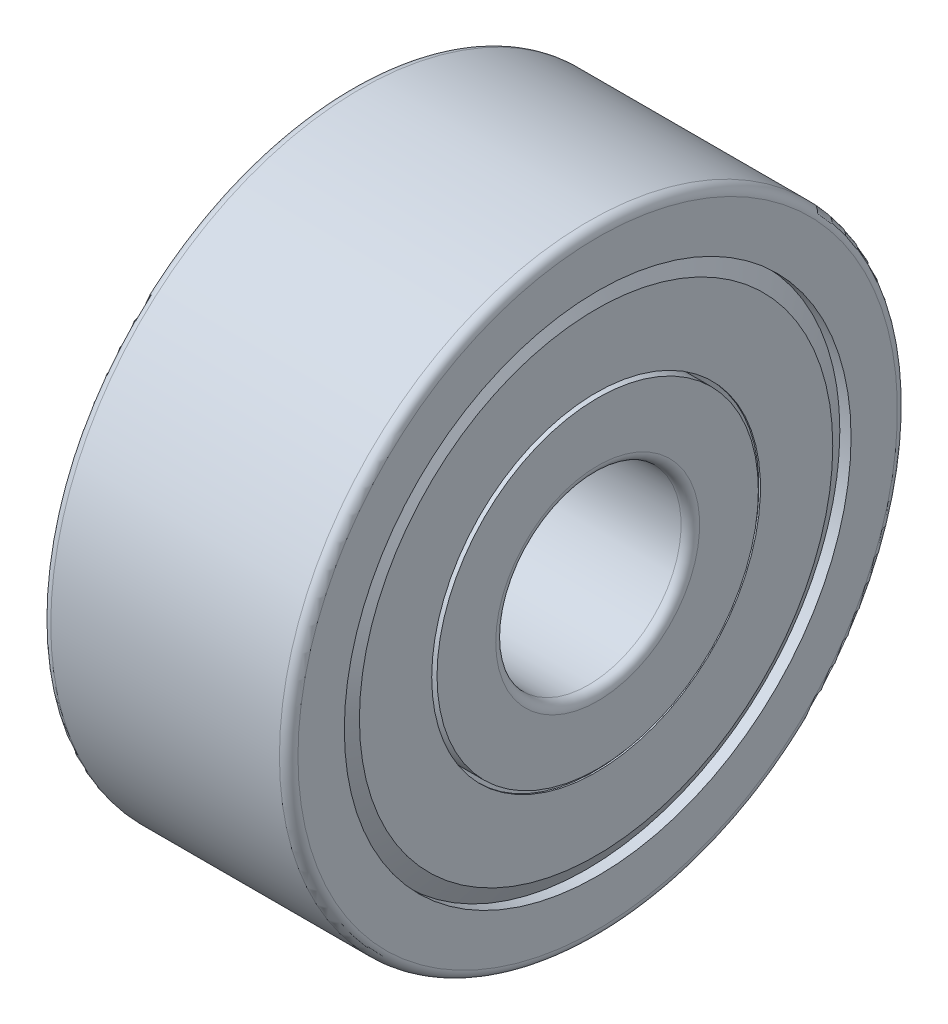
from build123d import *


with BuildPart() as part:
    # Esquisse1 → Révolution1 (revolve)
    with BuildSketch(Plane(origin=(0, 0, 0), x_dir=(-1, 0, 0), z_dir=(0, 0, -1))):
        with BuildLine():
            Line((-4, 2.6), (-4, 1.65))
            ThreePointArc((-4, 1.65), (-3.956066017, 1.543933983), (-3.85, 1.5))
            Line((-3.85, 1.5), (-0.15, 1.5))
            ThreePointArc((-0.15, 1.5), (-0.043933983, 1.543933983), (0, 1.65))
            Line((0, 1.65), (0, 2.6))
            Line((0, 2.6), (-0.887539014, 2.6))
            ThreePointArc((-0.887539014, 2.6), (-0.665814251, 3.208515617), (-0.754982151, 3.85))
            Line((-0.754982151, 3.85), (-0.363636364, 3.85))
            Line((-0.363636364, 3.85), (-0.363636364, 4.1))
            ThreePointArc((-0.363636364, 4.1), (-0.331965494, 4.168958654), (-0.259019853, 4.189869736))
            Line((-0.259019853, 4.189869736), (-0.261825318, 4.18825))
            Line((-0.261825318, 4.18825), (-0.051, 3.823089838))
            Line((-0.051, 3.823089838), (-0.051, 2.66))
            Line((-0.051, 2.66), (-0.026, 2.66))
            Line((-0.026, 2.66), (-0.026, 3.829788568))
            Line((-0.026, 3.829788568), (-0.227554836, 4.178891785))
            ThreePointArc((-0.227554836, 4.178891785), (-0.194079171, 4.145595382), (-0.181818182, 4.1))
            Line((-0.181818182, 4.1), (0, 4.1))
            Line((0, 4.1), (0, 4.85))
            ThreePointArc((0, 4.85), (-0.043933983, 4.956066017), (-0.15, 5))
            Line((-0.15, 5), (-3.85, 5))
            ThreePointArc((-3.85, 5), (-3.956066017, 4.956066017), (-4, 4.85))
            Line((-4, 4.85), (-4, 4.1))
            Line((-4, 4.1), (-3.818181818, 4.1))
            ThreePointArc((-3.818181818, 4.1), (-3.805920829, 4.145595382), (-3.772445164, 4.178891785))
            Line((-3.772445164, 4.178891785), (-3.974, 3.829788568))
            Line((-3.974, 3.829788568), (-3.974, 2.66))
            Line((-3.974, 2.66), (-3.949, 2.66))
            Line((-3.949, 2.66), (-3.949, 3.823089838))
            Line((-3.949, 3.823089838), (-3.738174682, 4.18825))
            Line((-3.738174682, 4.18825), (-3.740980147, 4.189869736))
            ThreePointArc((-3.740980147, 4.189869736), (-3.668034506, 4.168958654), (-3.636363636, 4.1))
            Line((-3.636363636, 4.1), (-3.636363636, 3.85))
            Line((-3.636363636, 3.85), (-3.245017849, 3.85))
            ThreePointArc((-3.245017849, 3.85), (-3.334185749, 3.208515617), (-3.112460986, 2.6))
            Line((-3.112460986, 2.6), (-4, 2.6))
        make_face()
    revolve(axis=Axis((4, 0, 0), (-1, 0, 0)))


solid = part.part
